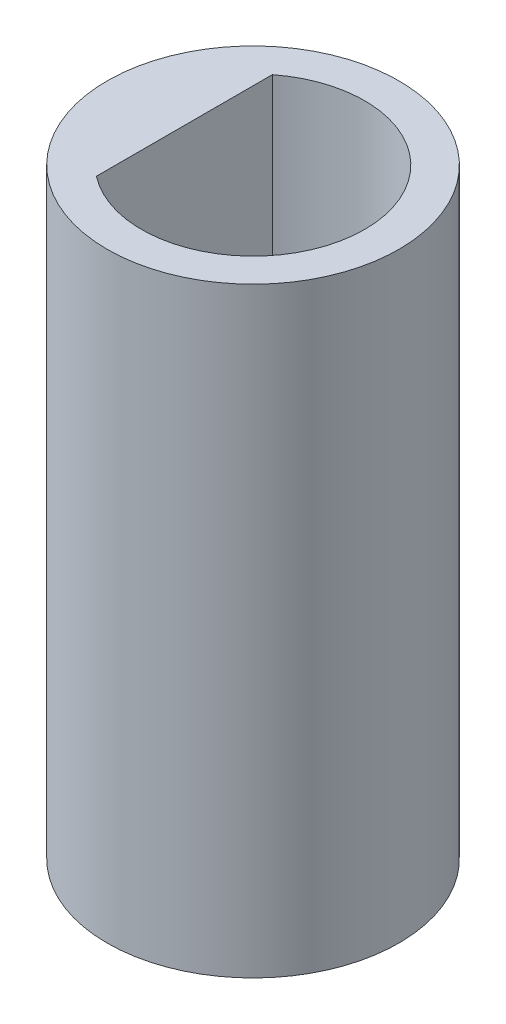
from build123d import *

# Parameters (mm, degrees)
CROQUIS2_R              = 3.4
SALIENTE_EXTRUIR1_DEPTH = 14
CORTAR_EXTRUIR1_DEPTH   = 15


with BuildPart() as part:
    # Croquis2 → Saliente-Extruir1 (new body)
    with BuildSketch(Plane(origin=(0, 0, 0), x_dir=(1, 0, 0), z_dir=(0, 1, 0))):
        Circle(CROQUIS2_R)
    extrude(amount=SALIENTE_EXTRUIR1_DEPTH)

    # Croquis3 → Cortar-Extruir1 (cut, through all)
    with BuildSketch(Plane(origin=(0, 14, 0), x_dir=(1, 0, 0), z_dir=(0, 1, 0))):
        with BuildLine():
            Line((-1.6, 2.049390153), (-1.6, -2.049390153))
            ThreePointArc((-1.6, -2.049390153), (2.6, 0), (-1.6, 2.049390153))
        make_face()
    extrude(amount=-CORTAR_EXTRUIR1_DEPTH, mode=Mode.SUBTRACT)


solid = part.part
